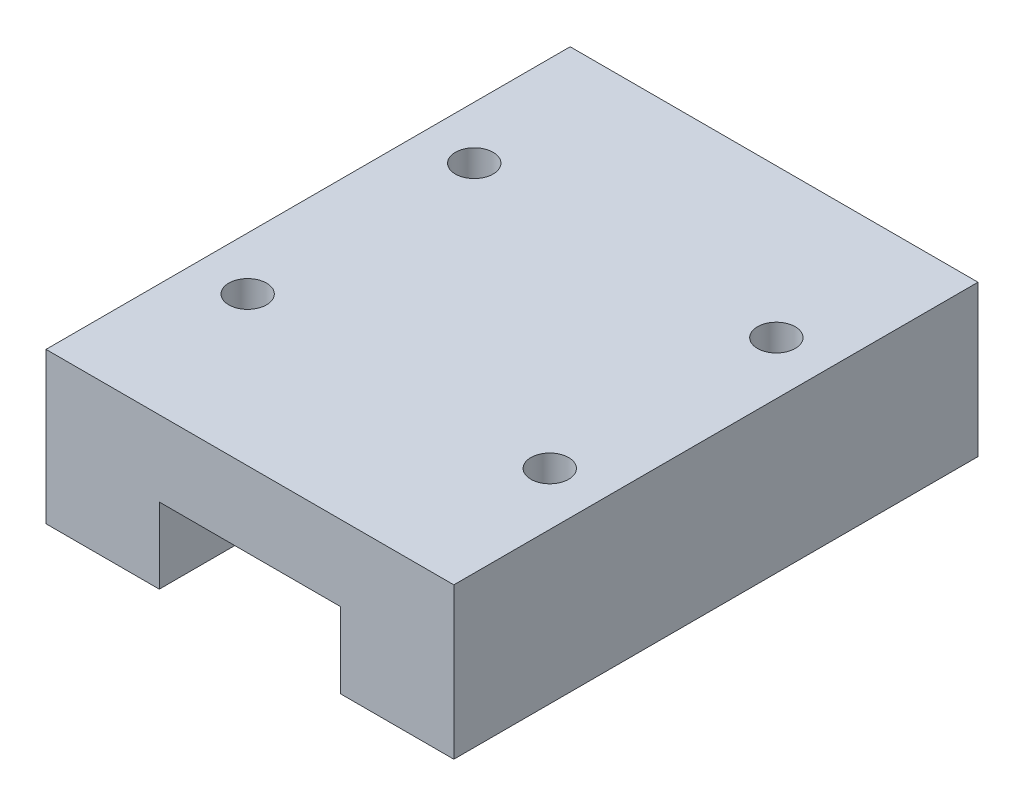
from build123d import *

# Parameters (mm, degrees)
BOSS_EXTRUDE1_DEPTH       = 34.7
M3X0_5_TAPPED_HOLE1_D     = 2.5
M3X0_5_TAPPED_HOLE1_DEPTH = 6
M3X0_5_TAPPED_HOLE1_TIP   = 0.751075774


with BuildPart() as part:
    # Sketch2 → Boss-Extrude1 (new body)
    with BuildSketch(Plane.XY):
        Polygon((0, 0), (0, 10), (27, 10), (27, 0), (19.5, 0), (19.5, 5), (7.5, 5), (7.5, 0), align=None)
    extrude(amount=BOSS_EXTRUDE1_DEPTH)

    # M3x0.5 Tapped Hole1
    with Locations(Plane(origin=(0, 10, 0), x_dir=(1, 0, 0), z_dir=(0, 1, 0))):
        with Locations((23.5, -9.85), (3.5, -9.85), (3.5, -24.85), (23.5, -24.85)):
            Hole(M3X0_5_TAPPED_HOLE1_D / 2, depth=M3X0_5_TAPPED_HOLE1_DEPTH)
            with Locations((0, 0, -(M3X0_5_TAPPED_HOLE1_DEPTH + M3X0_5_TAPPED_HOLE1_TIP / 2))):  # 118° drill point
                Cone(0, M3X0_5_TAPPED_HOLE1_D / 2, M3X0_5_TAPPED_HOLE1_TIP, mode=Mode.SUBTRACT)


solid = part.part
